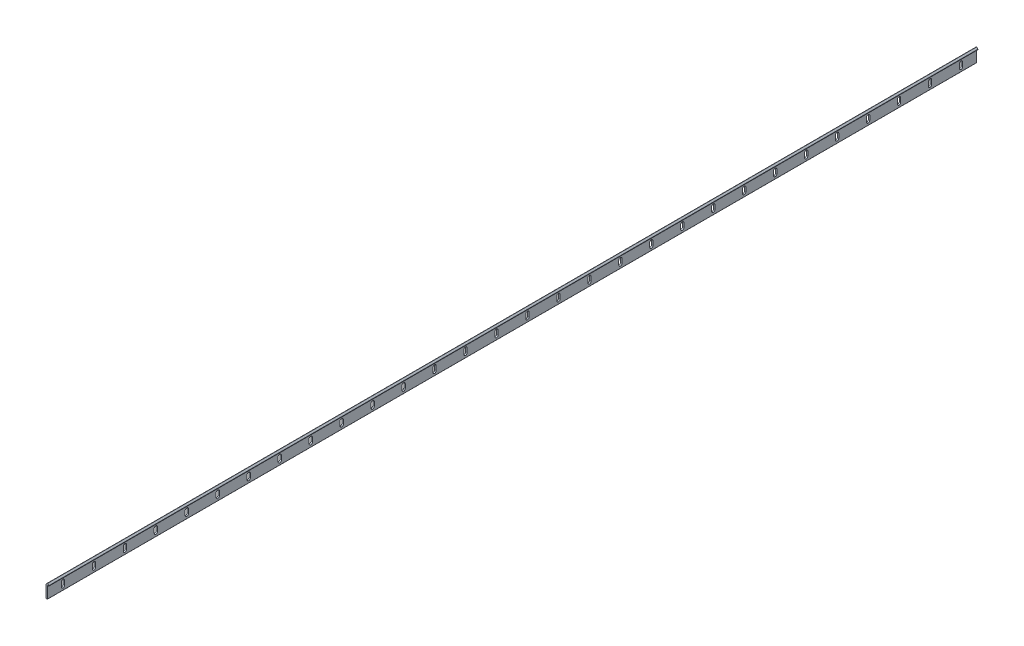
from build123d import *

# Parameters (mm, degrees)
BOSS_EXTRUDE1_DEPTH = 1500
CUT_EXTRUDE1_DEPTH  = 3.375
LPATTERN1_COUNT     = 30
LPATTERN1_PITCH     = 50


with BuildPart() as part:
    # Sketch1 → Boss-Extrude1 (new body)
    with BuildSketch(Plane.XY):
        with BuildLine():
            Line((0, 0.3), (0, 20.125))
            ThreePointArc((0, 20.125), (0.02283614, 20.23980503), (0.087867966, 20.337132034))
            Line((0.087867966, 20.337132034), (2.162867966, 22.412132034))
            ThreePointArc((2.162867966, 22.412132034), (2.375, 22.5), (2.587132034, 22.412132034))
            Line((2.587132034, 22.412132034), (4.662132034, 20.337132034))
            ThreePointArc((4.662132034, 20.337132034), (4.72716386, 20.23980503), (4.75, 20.125))
            Line((4.75, 20.125), (4.75, 19.85))
            ThreePointArc((4.75, 19.85), (4.662132034, 19.637867966), (4.45, 19.55))
            Line((4.45, 19.55), (2.375, 19.55))
            Line((2.375, 19.55), (2.375, 0.3))
            ThreePointArc((2.375, 0.3), (2.287132034, 0.087867966), (2.075, 0))
            Line((2.075, 0), (0.3, 0))
            ThreePointArc((0.3, 0), (0.087867966, 0.087867966), (0, 0.3))
        make_face()
    extrude(amount=BOSS_EXTRUDE1_DEPTH)

    # Sketch2 → Cut-Extrude1 (cut, through all)
    with BuildSketch(Plane(origin=(2.375, 0, 0), x_dir=(0, 0, -1), z_dir=(1, 0, 0))):
        with BuildLine():
            Line((-22.35, 12.7), (-22.35, 6))
            ThreePointArc((-22.35, 6), (-25, 3.35), (-27.65, 6))
            Line((-27.65, 6), (-27.65, 12.7))
            ThreePointArc((-27.65, 12.7), (-25, 15.35), (-22.35, 12.7))
        make_face()
    cut_extrude1 = extrude(amount=-CUT_EXTRUDE1_DEPTH, mode=Mode.SUBTRACT)

    # LPattern1: Cut-Extrude1 ×30
    with Locations(*[(0, 0, i * LPATTERN1_PITCH) for i in range(1, LPATTERN1_COUNT)]):
        add(cut_extrude1, mode=Mode.SUBTRACT)


solid = part.part
